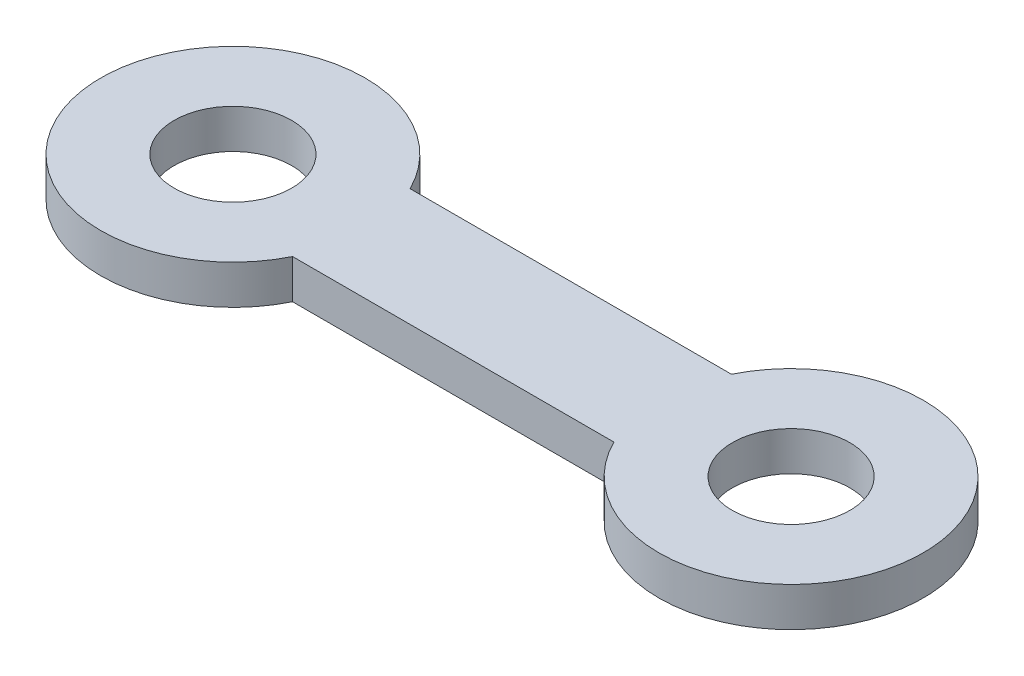
from build123d import *

# Parameters (mm, degrees)
SKETCH1_R           = 1.5
BOSS_EXTRUDE1_DEPTH = 1


with BuildPart() as part:
    # Sketch1 → Boss-Extrude1 (new body)
    with BuildSketch(Plane(origin=(0, 0, 0), x_dir=(1, 0, 0), z_dir=(0, 1, 0))):
        with BuildLine():
            Line((-3.023346656, 1.5), (-11.226653344, 1.5))
            ThreePointArc((-11.226653344, 1.5), (-17.625, 0), (-11.226653344, -1.5))
            Line((-11.226653344, -1.5), (-3.023346656, -1.5))
            ThreePointArc((-3.023346656, -1.5), (3.375, 0), (-3.023346656, 1.5))
        make_face()
        Circle(SKETCH1_R, mode=Mode.SUBTRACT)
        with Locations((-14.25, 0)):
            Circle(SKETCH1_R, mode=Mode.SUBTRACT)
    extrude(amount=BOSS_EXTRUDE1_DEPTH)


solid = part.part
